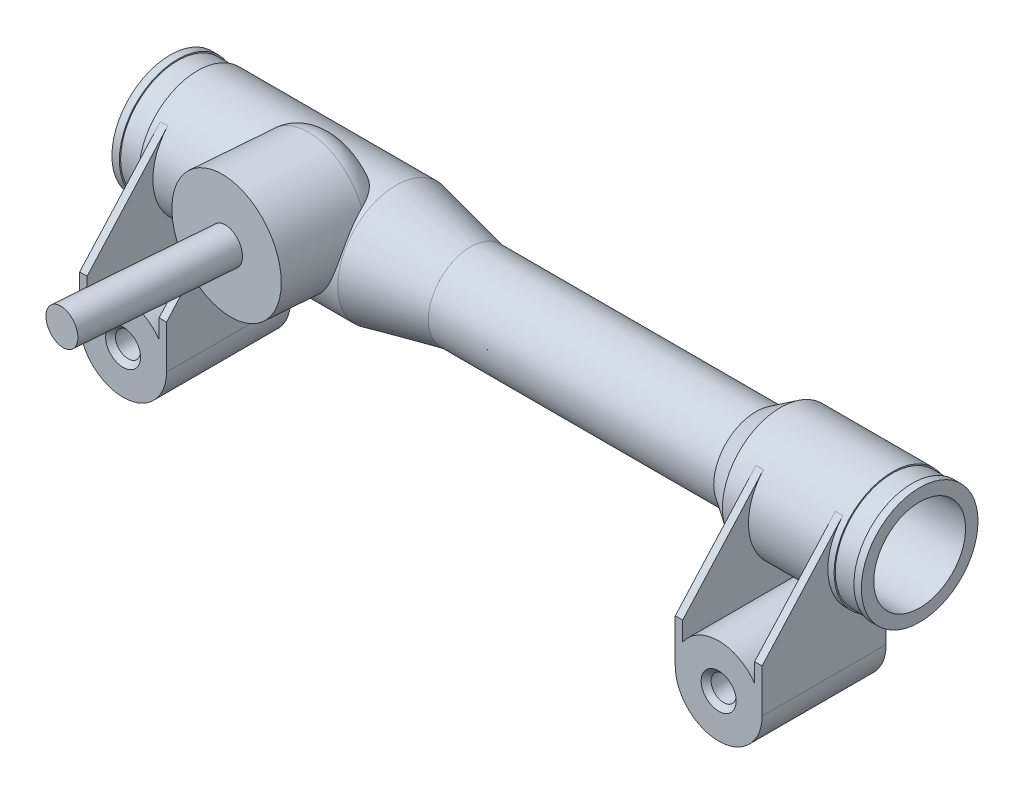
from build123d import *

# Parameters (mm, degrees)
SZKIC1_R                        = 23.5
DODANIE_WYCI_GNI_CIE1_DEPTH     = 302
SZKIC2_R                        = 17.5
DODANIE_WYCI_GNI_CIE2_DEPTH     = 50
SZKIC4_R                        = 17.5
DODANIE_WYCI_GNI_CIE3_DEPTH     = 50
SZKIC5_R                        = 5.05
WYTNIJ_WYCI_GNI_CIE1_DEPTH      = 50
SFAZOWANIE1_SIZE                = 2
SZKIC8_R                        = 24
DODANIE_WYCI_GNI_CIE4_DEPTH     = 42.129872
SZKIC12_R                       = 7
DODANIE_WYCI_GNI_CIE5_DEPTH     = 61.69017
SZKIC6_R                        = 11
WYTNIJ_WYCI_GNI_CIE2_DEPTH      = 302
SZKIC13_R                       = 7
DODANIE_WYCI_GNI_CIE6_DEPTH     = 50
DODANIE_WYCI_GNI_CIE7_START     = 14.5
DODANIE_WYCI_GNI_CIE7_DEPTH     = 3
ZAOKR_GLENIE1_R                 = 10
LUSTRO2_START                   = 14.5
LUSTRO2_COPY_1_DEPTH            = 3
WYTNIJ_WYCI_GNI_CIE3_START      = -3
SZKIC17_R                       = 23.5
SZKIC17_R_2                     = 23
WYTNIJ_WYCI_GNI_CIE3_DEPTH      = 8
SZKIC18_R                       = 23.5
SZKIC18_R_2                     = 17
WYTNIJ_WYCI_GNI_CIE4_DEPTH      = 60
WYTNIJ_WYCI_GNI_CIE4_DEPTH_BACK = 95
SZKIC20_R                       = 18.5
WYTNIJ_WYCI_GNI_CIE5_DEPTH      = 45


with BuildPart() as part:
    # Szkic1 → Dodanie-wyciągnięcie1 (new body)
    with BuildSketch(Plane(origin=(0, 0, 0), x_dir=(0, 0, -1), z_dir=(1, 0, 0))):
        Circle(SZKIC1_R)
    extrude(amount=DODANIE_WYCI_GNI_CIE1_DEPTH)

    # Szkic2 → Dodanie-wyciągnięcie2 (add)
    with BuildSketch(Plane.XY):
        with Locations((31, -38)):
            Circle(SZKIC2_R)
    extrude(amount=DODANIE_WYCI_GNI_CIE2_DEPTH)

    # Szkic4 → Dodanie-wyciągnięcie3 (add)
    with BuildSketch(Plane(origin=(0, 0, 0), x_dir=(-1, 0, 0), z_dir=(0, 0, -1))):
        with Locations((-271, -38)):
            Circle(SZKIC4_R)
    extrude(amount=-DODANIE_WYCI_GNI_CIE3_DEPTH)

    # Szkic5 → Wytnij-wyciągnięcie1 (cut)
    with BuildSketch(Plane.XY.offset(50)):
        with Locations((31, -38)):
            Circle(SZKIC5_R)
        with Locations((271, -38)):
            Circle(SZKIC5_R)
    extrude(amount=-WYTNIJ_WYCI_GNI_CIE1_DEPTH, mode=Mode.SUBTRACT)

    # Sfazowanie1
    sfazowanie1_edges = [part.edges().sort_by_distance(p)[0] for p in [
        (25.95, -38, 0),
        (25.95, -38, 50),
        (265.95, -38, 0),
        (265.95, -38, 50),
    ]]
    chamfer(sfazowanie1_edges, length=SFAZOWANIE1_SIZE)

    # Szkic8 → Dodanie-wyciągnięcie4 (add)
    with BuildSketch(Plane(origin=(64.694528313, 23.5, 42), x_dir=(0.996917334, 0, 0.078459096), z_dir=(-0.078459096, 0, 0.996917334))):
        with Locations((0, -13.25)):
            Circle(SZKIC8_R)
    extrude(amount=-DODANIE_WYCI_GNI_CIE4_DEPTH)

    # Szkic12 → Dodanie-wyciągnięcie5 (add)
    with BuildSketch(Plane(origin=(-2.886875267, 0, 36.681228189), x_dir=(0.996917334, 0, 0.078459096), z_dir=(-0.078459096, 0, 0.996917334))):
        with Locations((67.790378694, 10.25)):
            Circle(SZKIC12_R)
    extrude(amount=DODANIE_WYCI_GNI_CIE5_DEPTH)

    # Szkic6 → Wytnij-wyciągnięcie2 (cut)
    with BuildSketch(Plane.ZY):
        Circle(SZKIC6_R)
    extrude(amount=-WYTNIJ_WYCI_GNI_CIE2_DEPTH, mode=Mode.SUBTRACT)

    # Szkic13 → Dodanie-wyciągnięcie6 (add)
    with BuildSketch(Plane(origin=(64.694528313, 23.5, 42), x_dir=(0.996917334, 0, 0.078459096), z_dir=(-0.078459096, 0, 0.996917334))):
        with Locations((0, -13.25)):
            Circle(SZKIC13_R)
    extrude(amount=-DODANIE_WYCI_GNI_CIE6_DEPTH)

    # Szkic16 → Dodanie-wyciągnięcie7 (add)
    with BuildSketch(Plane.ZY.offset(-31).offset(DODANIE_WYCI_GNI_CIE7_START)):
        Polygon((50, -38), (0, -38), (0, -20.172556468), (13.849344331, -17.060101722), (21.580694053, -1.91951259), (17.483252048, 15.703053774), (50, -20.5), align=None)
    dodanie_wyci_gni_cie7 = extrude(amount=DODANIE_WYCI_GNI_CIE7_DEPTH)

    # Zaokrąglenie1
    zaokr_glenie1_edges = [part.edges().sort_by_distance(p)[0] for p in [
        (68.000000001, 34.25, 3.37e-07),
    ]]
    fillet(zaokr_glenie1_edges, radius=ZAOKR_GLENIE1_R)

    # Lustro1: Dodanie-wyciągnięcie7 across plane
    add(dodanie_wyci_gni_cie7.mirror(Plane.ZY.offset(-31)))

    # Lustro2: Dodanie-wyciągnięcie7 across plane
    add(dodanie_wyci_gni_cie7.mirror(Plane.ZY.offset(-151)))

    # Lustro2 copy 1 sketch → Lustro2 copy 1 (add)
    with BuildSketch(Plane.ZY.offset(-271).offset(LUSTRO2_START)):
        Polygon((50, -38), (0, -38), (0, -20.172556468), (13.849344331, -17.060101722), (21.580694053, -1.91951259), (17.483252048, 15.703053774), (50, -20.5), align=None)
    extrude(amount=LUSTRO2_COPY_1_DEPTH)

    # Szkic17 → Wytnij-wyciągnięcie3 (cut)
    with BuildSketch(Plane.ZY.offset(WYTNIJ_WYCI_GNI_CIE3_START)):
        Circle(SZKIC17_R)
        Circle(SZKIC17_R_2, mode=Mode.SUBTRACT)
    wytnij_wyci_gni_cie3 = extrude(amount=-WYTNIJ_WYCI_GNI_CIE3_DEPTH, mode=Mode.SUBTRACT)

    # Lustro3: Wytnij-wyciągnięcie3 across plane
    add(wytnij_wyci_gni_cie3.mirror(Plane.ZY.offset(-151)), mode=Mode.SUBTRACT)

    # Szkic18 → Wytnij-wyciągnięcie4 (cut, two sides)
    with BuildSketch(Plane.ZY.offset(-151)) as wytnij_wyci_gni_cie4_sk:
        Circle(SZKIC18_R)
        Circle(SZKIC18_R_2, mode=Mode.SUBTRACT)
    extrude(amount=WYTNIJ_WYCI_GNI_CIE4_DEPTH, mode=Mode.SUBTRACT)
    extrude(wytnij_wyci_gni_cie4_sk.sketch, amount=-WYTNIJ_WYCI_GNI_CIE4_DEPTH_BACK, mode=Mode.SUBTRACT)

    # Szkic19 → Obrót1 (revolve)
    with BuildSketch(Plane.XY):
        Polygon((91, 23.5), (91, 17), (121, 17), align=None)
        Polygon((246, 17), (246, 23.5), (236, 17), align=None)
    revolve(axis=Axis((0, 0, 0), (1, 0, 0)))

    # Szkic20 → Wytnij-wyciągnięcie5 (cut)
    with BuildSketch(Plane.ZY):
        Circle(SZKIC20_R)
    wytnij_wyci_gni_cie5 = extrude(amount=-WYTNIJ_WYCI_GNI_CIE5_DEPTH, mode=Mode.SUBTRACT)

    # Lustro4: Wytnij-wyciągnięcie5 across plane
    add(wytnij_wyci_gni_cie5.mirror(Plane.ZY.offset(-151)), mode=Mode.SUBTRACT)


solid = part.part
